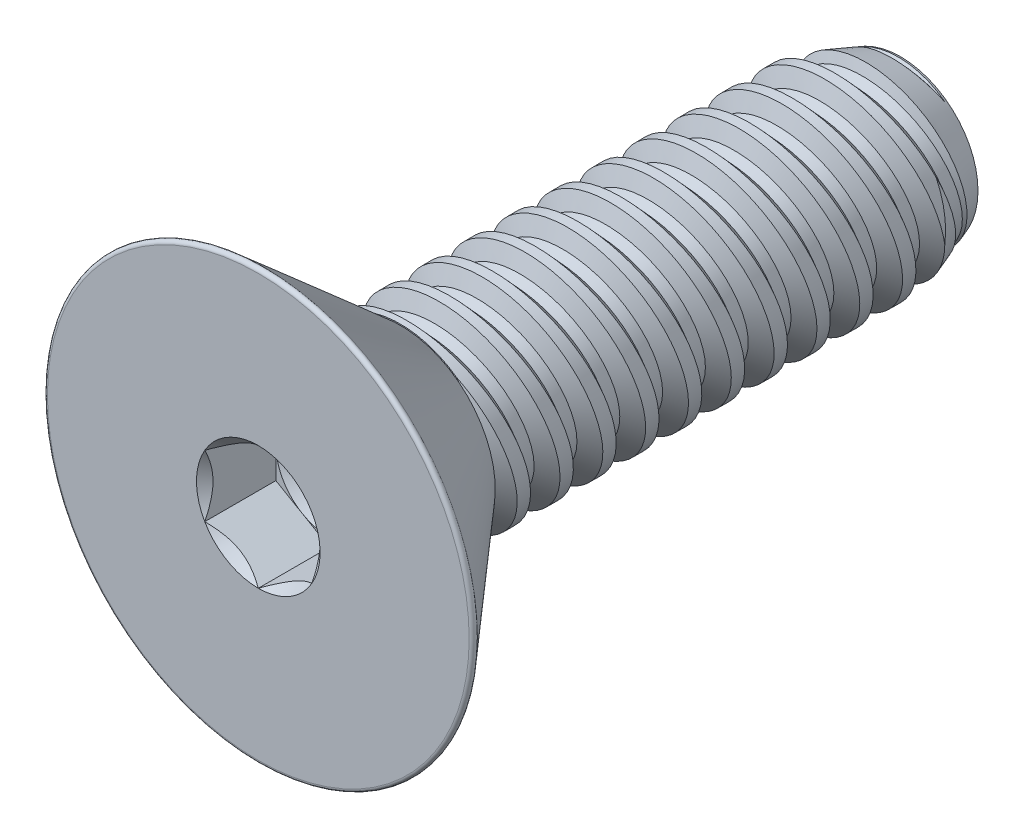
from build123d import *

# Parameters (mm, degrees)
SKETCH1_W          = 7.4168
SKETCH1_H          = 1.4224
LPATTERN1_COUNT    = 12
LPATTERN1_PITCH    = 0.635
LPATTERN2_COUNT    = 2
LPATTERN2_PITCH    = 0.635
SKETCH4_R          = 3.2385
EXTRUDE1_DEPTH     = 2.1082
FILLET1_R          = 0.0508
CUT_EXTRUDE1_DEPTH = 1.0541
SKETCH8_R          = 0.79375
CUT_EXTRUDE5_DEPTH = 0.351366667
CUT_EXTRUDE5_DRAFT = -60


with BuildPart() as part:
    # Sketch1 → Revolve1 (revolve)
    with BuildSketch(Plane(origin=(0, 0, 0), x_dir=(0, 0, -1), z_dir=(1, 0, 0)), mode=Mode.PRIVATE) as revolve1_sk:
        with Locations((3.7084, 0.7112)):
            Rectangle(SKETCH1_W, SKETCH1_H)
    revolve(revolve1_sk.sketch.rotate(Axis((0, 0, 0), (0, 0, 1)), 143.822582937), axis=Axis((0, 0, 0), (0, 0, 1)))

    # Sketch2 → Cut-Revolve1 (revolve, cut)
    with BuildSketch(Plane(origin=(0, 0, 0), x_dir=(0, 0, -1), z_dir=(1, 0, 0)), mode=Mode.PRIVATE) as cut_revolve1_sk:
        Polygon((0.077468538, 1.439692084), (0.619748307, 1.560736676), (0.500953883, 1.182057853), (0.346016806, 1.147473684), align=None)
    cut_revolve1 = revolve(cut_revolve1_sk.sketch.rotate(Axis((0, -0.152561988, 0), (0, 0.2178530325871702, -0.9759815859905213)), 180), axis=Axis((0, -0.152561988, 0), (0, 0.2178530325871702, -0.9759815859905213)), mode=Mode.SUBTRACT)

    # Sketch3 → Cut-Revolve2 (revolve, cut)
    with BuildSketch(Plane(origin=(0, 0, 0), x_dir=(0, 0, -1), z_dir=(1, 0, 0)), mode=Mode.PRIVATE) as cut_revolve2_sk:
        Polygon((7.4168, 1.147473684), (6.661446156, 1.4224), (7.4168, 1.4224), align=None)
    revolve(cut_revolve2_sk.sketch.rotate(Axis((0, 0, -6.661446156), (0, 0, 1)), 143.822582937), axis=Axis((0, 0, -6.661446156), (0, 0, 1)), mode=Mode.SUBTRACT)

    # LPattern1: Cut-Revolve1 ×12
    with Locations(*[(0, 0, -i * LPATTERN1_PITCH) for i in range(1, LPATTERN1_COUNT)]):
        add(cut_revolve1, mode=Mode.SUBTRACT)

    # LPattern2: Cut-Revolve1 ×2
    with Locations(*[(0, 0, i * LPATTERN2_PITCH) for i in range(1, LPATTERN2_COUNT)]):
        add(cut_revolve1, mode=Mode.SUBTRACT)

    # Sketch4 → Extrude1 (add)
    with BuildSketch(Plane.XY):
        Circle(SKETCH4_R)
    extrude(amount=EXTRUDE1_DEPTH)

    # Sketch9 → Cut-Revolve3 (revolve, cut)
    with BuildSketch(Plane(origin=(0, 0, 0), x_dir=(0, 0, -1), z_dir=(1, 0, 0)), mode=Mode.PRIVATE) as cut_revolve3_sk:
        Polygon((-2.1082, 3.2385), (0, 1.405869699), (0, 3.2385), align=None)
    revolve(cut_revolve3_sk.sketch.rotate(Axis((0, 0, 0), (0, 0, 1)), 180), axis=Axis((0, 0, 0), (0, 0, 1)), mode=Mode.SUBTRACT)

    # Fillet1
    fillet1_edges = [part.edges().sort_by_distance(p)[0] for p in [
        (0, 3.2385, 2.1082),
    ]]
    fillet(fillet1_edges, radius=FILLET1_R)

    # Sketch6 → Cut-Extrude1 (cut)
    with BuildSketch(Plane.XY.offset(2.1082)):
        Polygon((0, -0.916543552), (0.79375, -0.458271776), (0.79375, 0.458271776), (0, 0.916543552), (-0.79375, 0.458271776), (-0.79375, -0.458271776), align=None)
    extrude(amount=-CUT_EXTRUDE1_DEPTH, mode=Mode.SUBTRACT)

    # Cut-Extrude4 cone 1 section (through the dimple's axis) → Cut-Extrude4 (revolve, cut)
    with BuildSketch(Plane(origin=(0, 0, 2.1082), x_dir=(0, -1, 0), z_dir=(1, 0, 0))):
        Polygon((0, 0), (0.916543552, 0), (0, 0.916543552), align=None)
    revolve(axis=Axis((0, 0, 2.1082), (0, 0, -1)), mode=Mode.SUBTRACT)


with BuildPart() as cut_extrude5_tool:
    # Sketch8 → Cut-Extrude5 (with draft: the straight prism first)
    with BuildSketch(Plane.XY.offset(1.0541)):
        Circle(SKETCH8_R)
    extrude(amount=-CUT_EXTRUDE5_DEPTH)
    # Cut-Extrude5: the draft: its side faces are tilted about the plane it starts from
    cut_extrude5_sides = [cut_extrude5_tool.faces().sort_by_distance(p)[0] for p in [
        (-0.79375, 0, 0.878416667),
    ]]
    draft(cut_extrude5_sides, Plane.XY.offset(1.0541), CUT_EXTRUDE5_DRAFT)


with BuildPart() as part_1:
    add(part.part)

    # Cut-Extrude5: cut by cut_extrude5_tool
    add(cut_extrude5_tool.part, mode=Mode.SUBTRACT)


solid = part_1.part
